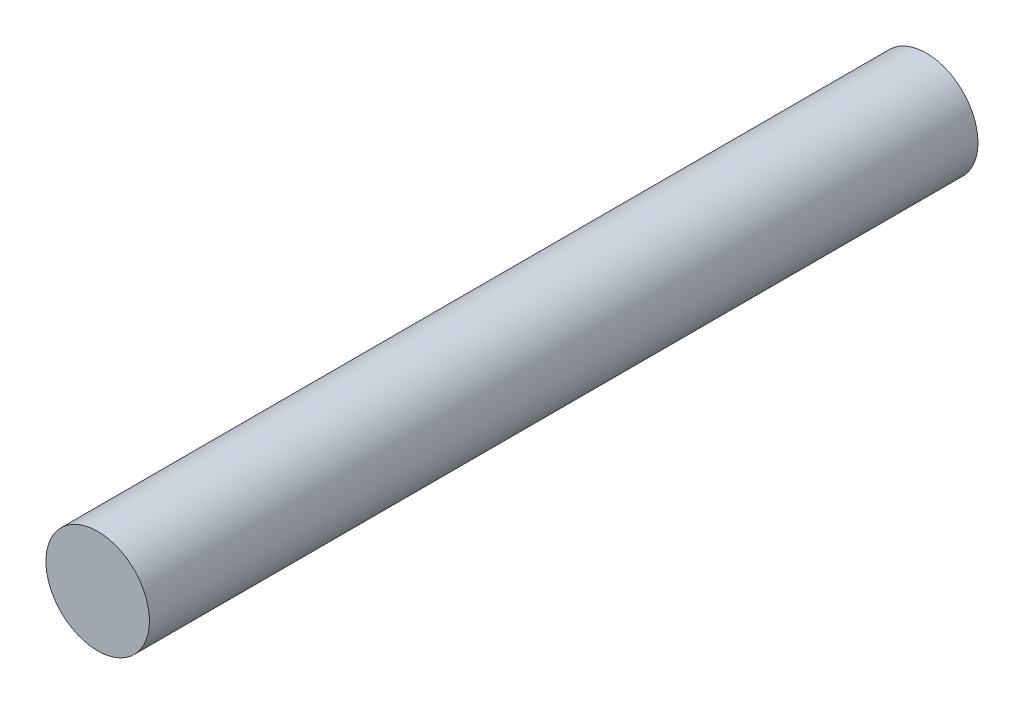
from build123d import *

# Parameters (mm, degrees)
SKETCH1_R           = 1.875
BOSS_EXTRUDE1_DEPTH = 30


with BuildPart() as part:
    # Sketch1 → Boss-Extrude1 (new body)
    with BuildSketch(Plane.XY):
        Circle(SKETCH1_R)
    extrude(amount=BOSS_EXTRUDE1_DEPTH)


solid = part.part
